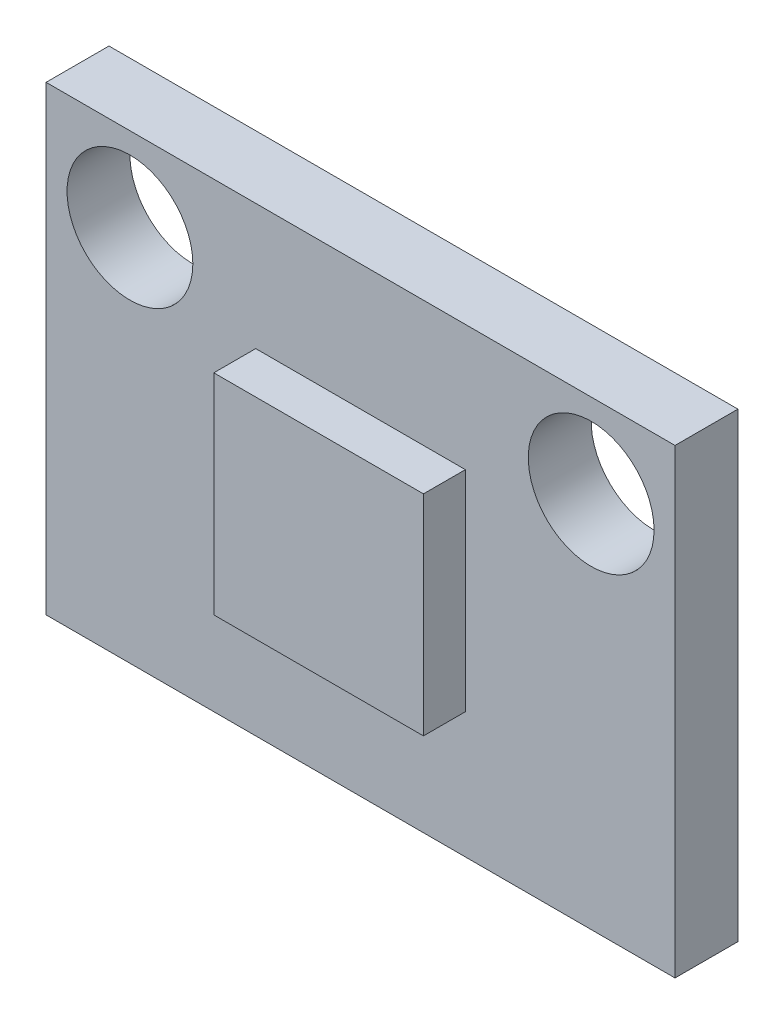
from build123d import *

# Parameters (mm, degrees)
SKETCH_1_W      = 15
SKETCH_1_H      = 11
SKETCH_1_R      = 1.5
EXTRUDE_1_DEPTH = 1.5
SKETCH_2_W      = 5
SKETCH_2_H      = 5
EXTRUDE_2_DEPTH = 1


with BuildPart() as part:
    # 草图1 → 凸台-拉伸1 (new body)
    with BuildSketch(Plane.XY):
        Rectangle(SKETCH_1_W, SKETCH_1_H)
        with Locations((-5.5, 3.5)):
            Circle(SKETCH_1_R, mode=Mode.SUBTRACT)
        with Locations((5.5, 3.5)):
            Circle(SKETCH_1_R, mode=Mode.SUBTRACT)
    extrude(amount=EXTRUDE_1_DEPTH)

    # 草图2 → 凸台-拉伸2 (add)
    with BuildSketch(Plane.XY.offset(1.5)):
        Rectangle(SKETCH_2_W, SKETCH_2_H)
    extrude(amount=EXTRUDE_2_DEPTH)


solid = part.part
